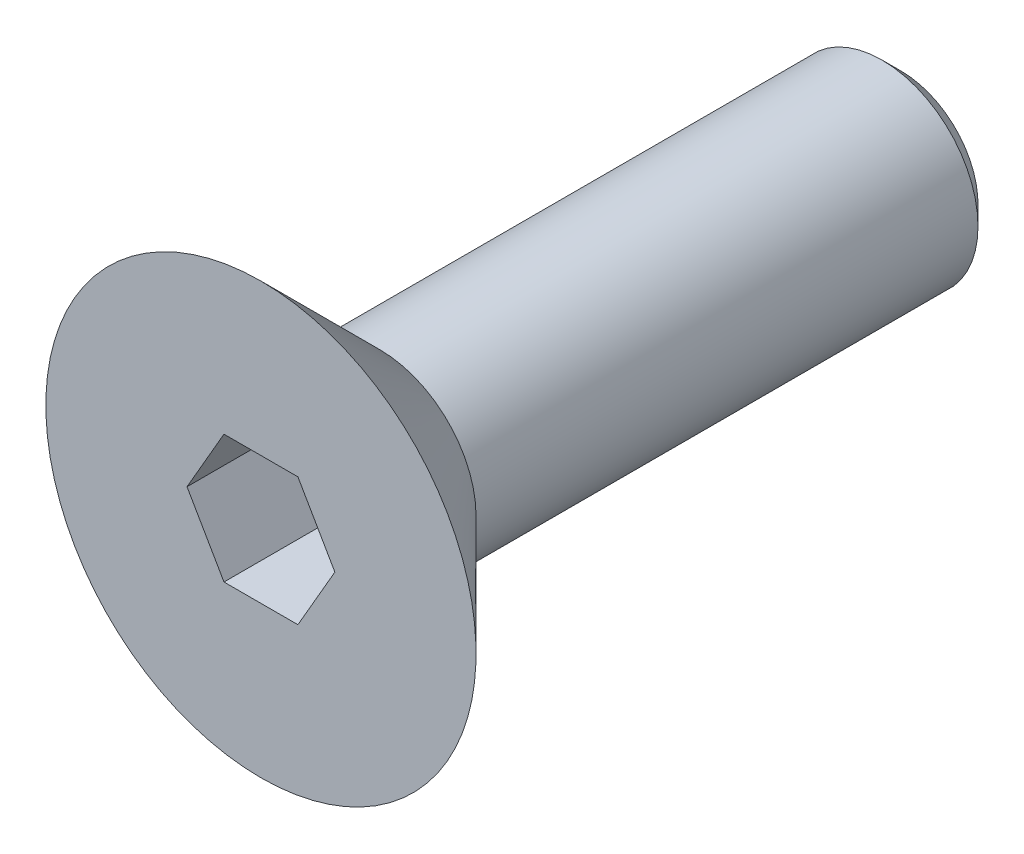
from build123d import *

# Parameters (mm, degrees)
CUT_EXTRUDE_1_DEPTH = 2
CHAMFER_1_SIZE      = 0.3


with BuildPart() as part:
    # Эскиз1 → Повернуть1 (revolve)
    with BuildSketch(Plane(origin=(0, 0, 0), x_dir=(0, 0, -1), z_dir=(1, 0, 0))):
        Polygon((0, 0), (0, 3.36), (1.86, 1.5), (10, 1.5), (10, 0), align=None)
    revolve(axis=Axis((0, 0, -10), (0, 0, 1)))

    # Эскиз2 → Вырез-Вытянуть1 (cut)
    with BuildSketch(Plane.XY):
        Polygon((1.154700538, 0), (0.577350269, 1), (-0.577350269, 1), (-1.154700538, 0), (-0.577350269, -1), (0.577350269, -1), align=None)
    extrude(amount=-CUT_EXTRUDE_1_DEPTH, mode=Mode.SUBTRACT)

    # Фаска1
    chamfer_1_edges = [part.edges().sort_by_distance(p)[0] for p in [
        (0, -1.5, -10),
    ]]
    chamfer(chamfer_1_edges, length=CHAMFER_1_SIZE)


solid = part.part
